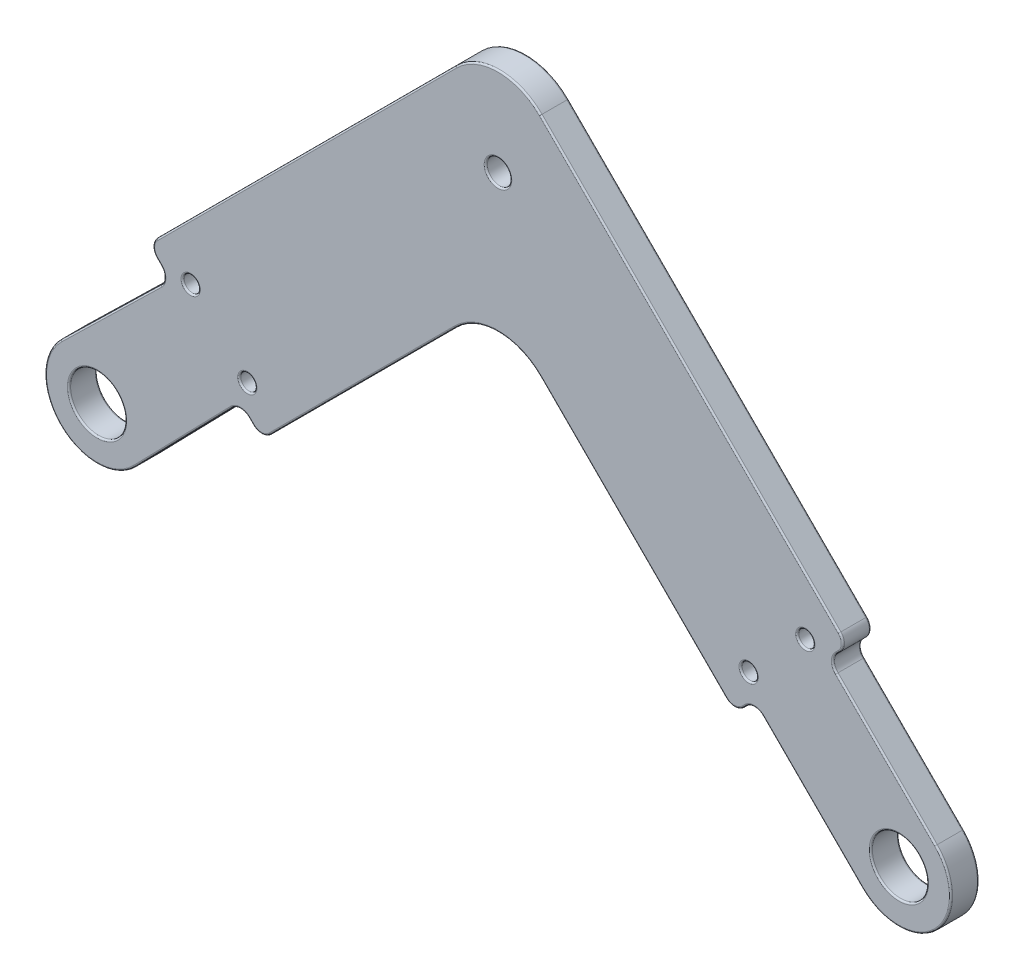
from build123d import *

# Parameters (mm, degrees)
SKETCH3_R           = 3.5
SKETCH3_R_2         = 1
BOSS_EXTRUDE1_DEPTH = 3.5
FILLET3_R           = 1.5
FILLET4_R           = 7.5
SKETCH4_R           = 1.524
CUT_EXTRUDE1_DEPTH  = 3.5
FILLET5_R           = 0.2


with BuildPart() as part:
    # Sketch3 → Boss-Extrude1 (new body)
    with BuildSketch(Plane.XY):
        with BuildLine():
            Line((-95.342398812, -4.533955357), (-82.149090724, 9.019148409))
            Line((-82.149090724, 9.019148409), (-79.493903346, 6.363961031))
            Line((-79.493903346, 6.363961031), (-50, 35.857864376))
            Line((-50, 35.857864376), (-20.506096654, 6.363961031))
            Line((-20.506096654, 6.363961031), (-18.03122292, 8.838834765))
            Line((-18.03122292, 8.838834765), (-4.596194078, -4.596194078))
            ThreePointArc((-4.596194078, -4.596194078), (4.596194078, -4.596194078), (4.596194078, 4.596194078))
            Line((4.596194078, 4.596194078), (-8.838834765, 18.03122292))
            Line((-8.838834765, 18.03122292), (-6.363961031, 20.506096654))
            Line((-6.363961031, 20.506096654), (-50, 64.142135624))
            Line((-50, 64.142135624), (-93.636038969, 20.506096654))
            Line((-93.636038969, 20.506096654), (-90.980851591, 17.850909276))
            Line((-90.980851591, 17.850909276), (-104.533955357, 4.657601188))
            ThreePointArc((-104.533955357, 4.657601188), (-104.596194078, -4.596194078), (-95.342398812, -4.533955357))
        make_face()
        Circle(SKETCH3_R, mode=Mode.SUBTRACT)
        with Locations((-100, 0)):
            Circle(SKETCH3_R, mode=Mode.SUBTRACT)
        with Locations((-18.738329701, 11.66726189)):
            Circle(SKETCH3_R_2, mode=Mode.SUBTRACT)
        with Locations((-81.261670299, 11.66726189)):
            Circle(SKETCH3_R_2, mode=Mode.SUBTRACT)
        with Locations((-88.33273811, 18.738329701)):
            Circle(SKETCH3_R_2, mode=Mode.SUBTRACT)
        with Locations((-11.66726189, 18.738329701)):
            Circle(SKETCH3_R_2, mode=Mode.SUBTRACT)
    extrude(amount=BOSS_EXTRUDE1_DEPTH)

    # Fillet3
    fillet3_edges = [part.edges().sort_by_distance(p)[0] for p in [
        (-82.149090724, 9.019148409, 1.75),
        (-90.980851591, 17.850909276, 1.75),
        (-93.636038969, 20.506096654, 1.75),
        (-6.363961031, 20.506096654, 1.75),
        (-8.838834765, 18.03122292, 1.75),
        (-18.03122292, 8.838834765, 1.75),
        (-20.506096654, 6.363961031, 1.75),
        (-79.493903346, 6.363961031, 1.75),
    ]]
    fillet(fillet3_edges, radius=FILLET3_R)

    # Fillet4
    fillet4_edges = [part.edges().sort_by_distance(p)[0] for p in [
        (-50, 64.142135624, 1.75),
        (-50, 35.857864376, 1.75),
    ]]
    fillet(fillet4_edges, radius=FILLET4_R)

    # Sketch4 → Cut-Extrude1 (cut)
    with BuildSketch(Plane.XY.offset(3.5)):
        with Locations((-50, 50)):
            Circle(SKETCH4_R)
    extrude(amount=-CUT_EXTRUDE1_DEPTH, mode=Mode.SUBTRACT)

    # Fillet5
    fillet5_edges = [part.edges().sort_by_distance(p)[0] for p in [
        (-33.131727984, 18.98959236, 0),
        (-33.131727984, 18.98959236, 3.5),
        (-73.939339828, 40.202795796, 0),
        (-73.939339828, 40.202795796, 3.5),
        (-50, 61.035533906, 0),
        (-50, 61.035533906, 3.5),
        (-50, 32.751262658, 0),
        (-50, 32.751262658, 3.5),
        (-51.524, 50, 0),
        (-51.524, 50, 3.5),
        (-89.275978249, 1.697903009, 0),
        (-104.596194078, -4.596194078, 0),
        (-1.590990258, 10.783378413, 0),
        (4.596194078, -4.596194078, 0),
        (4.596194078, -4.596194078, 3.5),
        (-1.590990258, 10.783378413, 3.5),
        (-3.5, 0, 0),
        (-3.5, 0, 3.5),
        (-103.5, 0, 0),
        (-103.5, 0, 3.5),
        (-19.738329701, 11.66726189, 0),
        (-19.738329701, 11.66726189, 3.5),
        (-82.261670299, 11.66726189, 0),
        (-82.261670299, 11.66726189, 3.5),
        (-89.33273811, 18.738329701, 0),
        (-89.33273811, 18.738329701, 3.5),
        (-104.596194078, -4.596194078, 3.5),
        (-12.66726189, 18.738329701, 0),
        (-12.66726189, 18.738329701, 3.5),
        (-89.275978249, 1.697903009, 3.5),
        (-80.814314994, 7.684372679, 0),
        (-80.814314994, 7.684372679, 3.5),
        (-66.868272016, 18.98959236, 0),
        (-66.868272016, 18.98959236, 3.5),
        (-98.302096991, 10.724021751, 0),
        (-92.315627321, 19.185685006, 0),
        (-26.060660172, 40.202795796, 0),
        (-7.601397898, 19.268659787, 0),
        (-10.783378413, 1.590990258, 0),
        (-19.268659787, 7.601397898, 0),
        (-6.985281374, 20.506096654, 0),
        (-20.506096654, 6.985281374, 0),
        (-93.014718626, 20.506096654, 0),
        (-79.493903346, 6.985281374, 0),
        (-19.268659787, 7.601397898, 3.5),
        (-10.783378413, 1.590990258, 3.5),
        (-7.601397898, 19.268659787, 3.5),
        (-26.060660172, 40.202795796, 3.5),
        (-92.315627321, 19.185685006, 3.5),
        (-98.302096991, 10.724021751, 3.5),
        (-6.985281374, 20.506096654, 3.5),
        (-20.506096654, 6.985281374, 3.5),
        (-93.014718626, 20.506096654, 3.5),
        (-79.493903346, 6.985281374, 3.5),
        (-82.144815041, 8.383430059, 0),
        (-82.144815041, 8.383430059, 3.5),
        (-91.616569941, 17.855184959, 0),
        (-91.616569941, 17.855184959, 3.5),
        (-18.03122292, 8.217514421, 0),
        (-18.03122292, 8.217514421, 3.5),
        (-8.217514421, 18.03122292, 0),
        (-8.217514421, 18.03122292, 3.5),
    ]]
    fillet(fillet5_edges, radius=FILLET5_R)


solid = part.part
